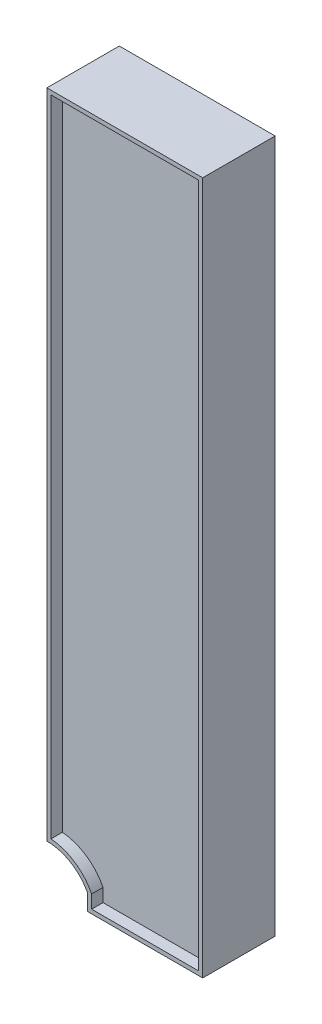
from build123d import *

# Parameters (mm, degrees)
SKETCH1_W           = 191.44
SKETCH1_H           = 851.41
BOSS_EXTRUDE1_DEPTH = 89
CUT_EXTRUDE1_DEPTH  = 89
CUT_EXTRUDE2_DEPTH  = 14


with BuildPart() as part:
    # Sketch1 → Boss-Extrude1 (new body)
    with BuildSketch(Plane.XY):
        with Locations((95.72, 425.705)):
            Rectangle(SKETCH1_W, SKETCH1_H)
    extrude(amount=BOSS_EXTRUDE1_DEPTH)

    # Sketch2 → Cut-Extrude1 (cut)
    with BuildSketch(Plane.XY.offset(89)):
        with BuildLine():
            Line((50, 0), (50, 20))
            ThreePointArc((50, 20), (29.154759474, 41.924599124), (0, 50))
            Line((0, 50), (-42.502715258, 50))
            Line((-42.502715258, 50), (0, -54.761569713))
            Line((0, -54.761569713), (50, 0))
        make_face()
    extrude(amount=-CUT_EXTRUDE1_DEPTH, mode=Mode.SUBTRACT)

    # Sketch3 → Cut-Extrude2 (cut)
    with BuildSketch(Plane.XY.offset(89)):
        with BuildLine():
            Line((55, 21.222000884), (55, 5))
            Line((55, 5), (186.44, 5))
            Line((186.44, 5), (186.44, 846.41))
            Line((186.44, 846.41), (5, 846.41))
            Line((5, 846.41), (5, 54.796963049))
            ThreePointArc((5, 54.796963049), (34.377602026, 44.528628593), (55, 21.222000884))
        make_face()
    cut_extrude2 = extrude(amount=-CUT_EXTRUDE2_DEPTH, mode=Mode.SUBTRACT)

    # Mirror1: Cut-Extrude2 across plane
    add(cut_extrude2.mirror(Plane.XY.offset(44.5)), mode=Mode.SUBTRACT)


solid = part.part
